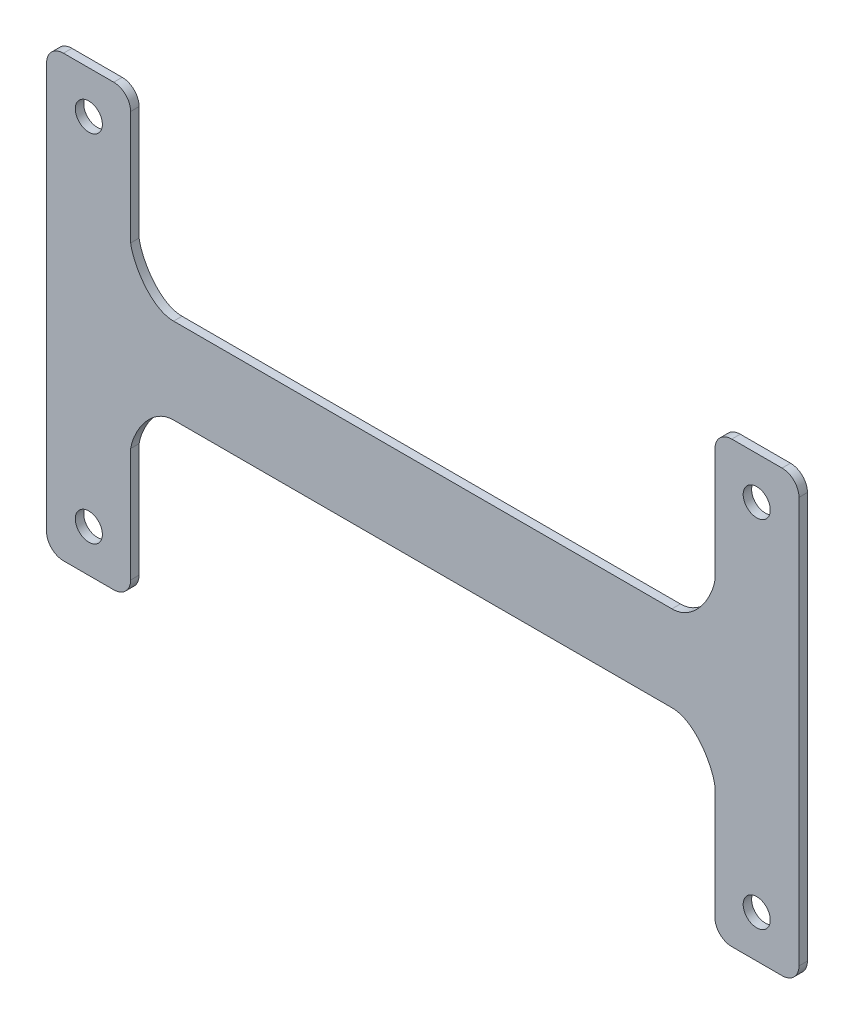
from build123d import *

# Parameters (mm, degrees)
EXTRUDE_1_DEPTH     = 1
SKETCH_2_R          = 1.6
CUT_EXTRUDE_1_DEPTH = 4
FILLET_3_R          = 2
FILLET_4_R          = 2
FILLET_5_R          = 2
FILLET_6_R          = 2
FILLET_7_R          = 2
FILLET_8_R          = 2
FILLET_9_R          = 2
FILLET_10_R         = 2


with BuildPart() as part:
    # 草图1 → 凸台-拉伸1 (new body)
    with BuildSketch(Plane.XY):
        with BuildLine():
            Line((-34.555089852, 10.529608301), (-34.555089852, 26))
            Line((-34.555089852, 26), (-44.5, 26))
            Line((-44.5, 26), (-44.5, -26))
            Line((-44.5, -26), (-34.555089852, -26))
            Line((-34.555089852, -26), (-34.555089852, -10.529608301))
            add(Edge.make_bspline(
                [(-34.555089852, -10.529608301), (-34.215666053, -8.393494982), (-32.082061244, -5.04423915), (-29.471557065, -5.067226444)],
                knots=[0, 0, 0, 0, 1, 1, 1, 1], degree=3))
            Line((-29.471557065, -5.067226444), (29.471557065, -5.067226444))
            add(Edge.make_bspline(
                [(34.555089852, -10.529608301), (34.215666053, -8.393494982), (32.082061244, -5.04423915), (29.471557065, -5.067226444)],
                knots=[0, 0, 0, 0, 1, 1, 1, 1], degree=3))
            Line((34.555089852, -10.529608301), (34.555089852, -26))
            Line((34.555089852, -26), (44.5, -26))
            Line((44.5, -26), (44.5, 26))
            Line((44.5, 26), (34.555089852, 26))
            Line((34.555089852, 26), (34.555089852, 10.529608301))
            add(Edge.make_bspline(
                [(34.555089852, 10.529608301), (34.215666053, 8.393494982), (32.082061244, 5.04423915), (29.471557065, 5.067226444)],
                knots=[0, 0, 0, 0, 1, 1, 1, 1], degree=3))
            Line((29.471557065, 5.067226444), (-29.471557065, 5.067226444))
            add(Edge.make_bspline(
                [(-34.555089852, 10.529608301), (-34.215666053, 8.393494982), (-32.082061244, 5.04423915), (-29.471557065, 5.067226444)],
                knots=[0, 0, 0, 0, 1, 1, 1, 1], degree=3))
        make_face()
    extrude(amount=-EXTRUDE_1_DEPTH)

    # 草图2 → 切除-拉伸1 (cut)
    with BuildSketch(Plane.XY):
        with Locations((-39.5, 21)):
            Circle(SKETCH_2_R)
        with Locations((39.5, 21)):
            Circle(SKETCH_2_R)
        with Locations((-39.5, -21)):
            Circle(SKETCH_2_R)
        with Locations((39.5, -21)):
            Circle(SKETCH_2_R)
    extrude(amount=-CUT_EXTRUDE_1_DEPTH, mode=Mode.SUBTRACT)

    # 圆角3
    fillet_3_edges = [part.edges().sort_by_distance(p)[0] for p in [
        (-44.5, 26, -0.5),
    ]]
    fillet(fillet_3_edges, radius=FILLET_3_R)

    # 圆角4
    fillet_4_edges = [part.edges().sort_by_distance(p)[0] for p in [
        (-34.555089852, 26, -0.5),
    ]]
    fillet(fillet_4_edges, radius=FILLET_4_R)

    # 圆角5
    fillet_5_edges = [part.edges().sort_by_distance(p)[0] for p in [
        (-44.5, -26, -0.5),
    ]]
    fillet(fillet_5_edges, radius=FILLET_5_R)

    # 圆角6
    fillet_6_edges = [part.edges().sort_by_distance(p)[0] for p in [
        (-34.555089852, -26, -0.5),
    ]]
    fillet(fillet_6_edges, radius=FILLET_6_R)

    # 圆角7
    fillet_7_edges = [part.edges().sort_by_distance(p)[0] for p in [
        (34.555089852, -26, -0.5),
    ]]
    fillet(fillet_7_edges, radius=FILLET_7_R)

    # 圆角8
    fillet_8_edges = [part.edges().sort_by_distance(p)[0] for p in [
        (44.5, -26, -0.5),
    ]]
    fillet(fillet_8_edges, radius=FILLET_8_R)

    # 圆角9
    fillet_9_edges = [part.edges().sort_by_distance(p)[0] for p in [
        (34.555089852, 26, -0.5),
    ]]
    fillet(fillet_9_edges, radius=FILLET_9_R)

    # 圆角10
    fillet_10_edges = [part.edges().sort_by_distance(p)[0] for p in [
        (44.5, 26, -0.5),
    ]]
    fillet(fillet_10_edges, radius=FILLET_10_R)


solid = part.part
